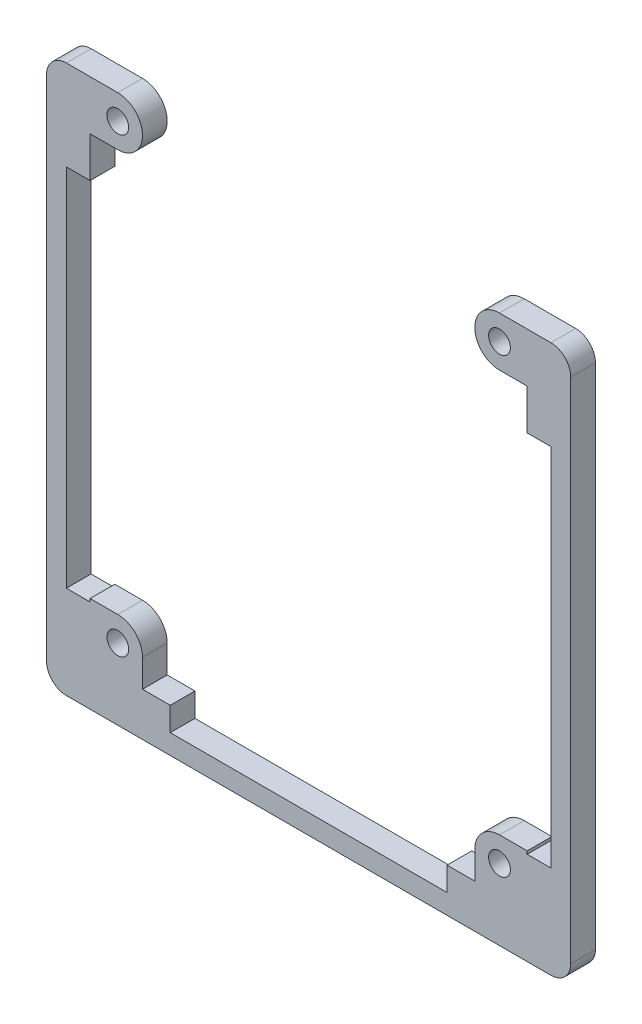
from build123d import *

# Parameters (mm, degrees)
SKETCH1_R           = 3.175
SKETCH1_R_2         = 1.397
BOSS_EXTRUDE1_DEPTH = 3.175


with BuildPart() as part:
    # Sketch1 → Boss-Extrude1 (new body)
    with BuildSketch(Plane.XY):
        with BuildLine():
            Line((0, 58.42), (0, 53.213))
            Line((0, 53.213), (3.048, 53.213))
            Line((3.048, 53.213), (3.048, 6.35))
            Line((3.048, 6.35), (0, 6.35))
            Line((0, 6.35), (0, 6.731))
            Line((0, 6.731), (-3.556, 6.731))
            ThreePointArc((-3.556, 6.731), (-1.31093597, 5.80106403), (-0.381, 3.556))
            ThreePointArc((-0.381, 3.556), (-3.556, 0.381), (-6.731, 3.556))
            Line((-6.731, 3.556), (-6.731, 0))
            Line((-6.731, 0), (-10.287, 0))
            Line((-10.287, 0), (-10.287, -3.048))
            Line((-10.287, -3.048), (-45.847, -3.048))
            Line((-45.847, -3.048), (-45.847, 0))
            Line((-45.847, 0), (-49.403, 0))
            Line((-49.403, 0), (-49.403, 3.556))
            ThreePointArc((-49.403, 3.556), (-54.82306403, 1.31093597), (-52.578, 6.731))
            Line((-52.578, 6.731), (-56.134, 6.731))
            Line((-56.134, 6.731), (-56.134, 6.35))
            Line((-56.134, 6.35), (-59.182, 6.35))
            Line((-59.182, 6.35), (-59.182, 53.213))
            Line((-59.182, 53.213), (-56.134, 53.213))
            Line((-56.134, 53.213), (-56.134, 58.42))
            Line((-56.134, 58.42), (-52.578, 58.42))
            ThreePointArc((-52.578, 58.42), (-55.753, 61.595), (-52.578, 64.77))
            Line((-52.578, 64.77), (-59.182, 64.77))
            ThreePointArc((-59.182, 64.77), (-60.978051224, 64.026051224), (-61.722, 62.23))
            Line((-61.722, 62.23), (-61.722, -3.048))
            ThreePointArc((-61.722, -3.048), (-60.978051224, -4.844051224), (-59.182, -5.588))
            Line((-59.182, -5.588), (3.048, -5.588))
            ThreePointArc((3.048, -5.588), (4.844051224, -4.844051224), (5.588, -3.048))
            Line((5.588, -3.048), (5.588, 62.23))
            ThreePointArc((5.588, 62.23), (4.844051224, 64.026051224), (3.048, 64.77))
            Line((3.048, 64.77), (-3.556000021, 64.77))
            ThreePointArc((-3.556000021, 64.77), (-1.310935977, 63.840064038), (-0.381, 61.595))
            ThreePointArc((-0.381, 61.595), (-1.31093597, 59.34993597), (-3.556, 58.42))
            Line((-3.556, 58.42), (0, 58.42))
        make_face()
        with Locations((-52.578, 61.595)):
            Circle(SKETCH1_R)
        with Locations((-52.578, 61.595)):
            Circle(SKETCH1_R_2, mode=Mode.SUBTRACT)
        with Locations((-3.556, 61.595)):
            Circle(SKETCH1_R)
        with Locations((-3.556, 61.595)):
            Circle(SKETCH1_R_2, mode=Mode.SUBTRACT)
        with Locations((-52.578, 3.556)):
            Circle(SKETCH1_R)
        with Locations((-52.578, 3.556)):
            Circle(SKETCH1_R_2, mode=Mode.SUBTRACT)
        with Locations((-3.556, 3.556)):
            Circle(SKETCH1_R)
        with Locations((-3.556, 3.556)):
            Circle(SKETCH1_R_2, mode=Mode.SUBTRACT)
    extrude(amount=BOSS_EXTRUDE1_DEPTH)


solid = part.part
